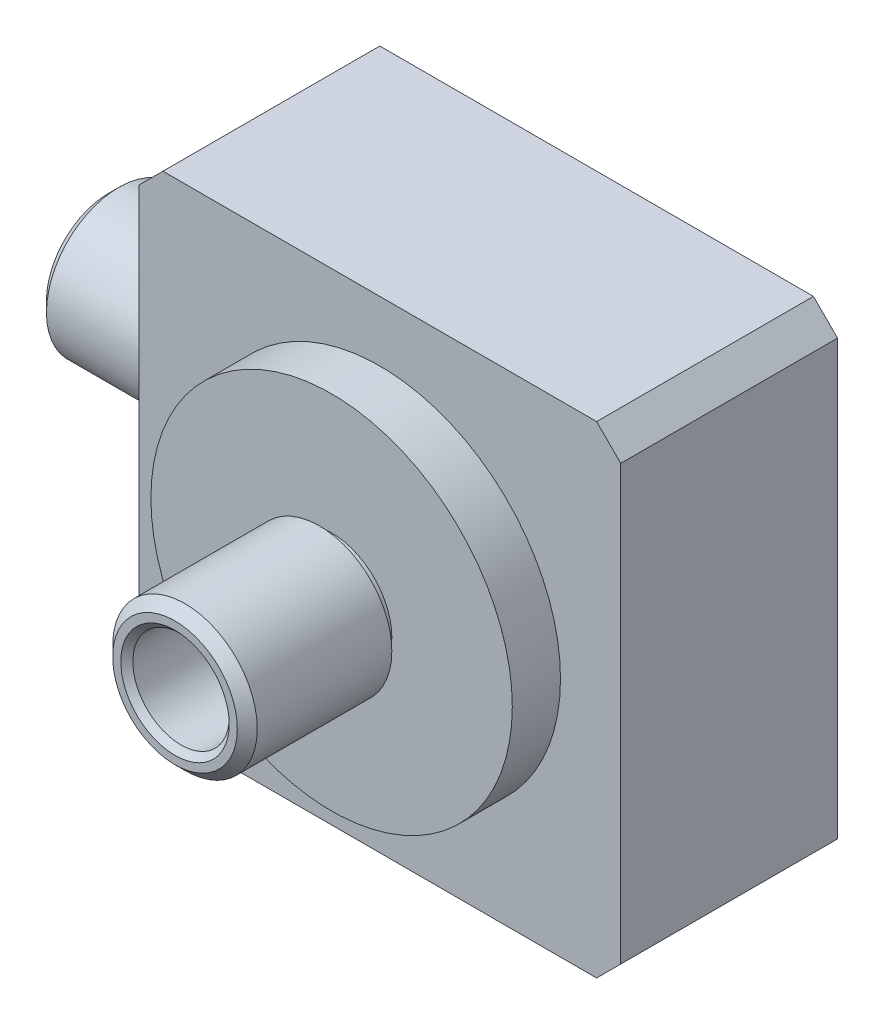
from build123d import *

# Parameters (mm, degrees)
SKETCH_1_W          = 40
SKETCH_1_H          = 40
EXTRUDE_1_DEPTH     = 18
SKETCH_2_R          = 15
EXTRUDE_2_DEPTH     = 4
SKETCH_3_R          = 5
EXTRUDE_3_DEPTH     = 1
SKETCH_4_R          = 6
EXTRUDE_4_DEPTH     = 12
SKETCH_5_R          = 5
EXTRUDE_5_DEPTH     = 1
SKETCH_6_R          = 6
EXTRUDE_6_DEPTH     = 12.5
SKETCH_8_R          = 2.5
CUT_EXTRUDE_1_DEPTH = 36
SKETCH_9_R          = 4
CUT_EXTRUDE_2_DEPTH = 10
CUT_EXTRUDE_3_REACH = 55.5
SKETCH_10_R         = 2.5
SKETCH_11_R         = 4
CUT_EXTRUDE_4_DEPTH = 10
CHAMFER_1_SIZE      = 0.5
CHAMFER_2_SIZE      = 0.828
CHAMFER_3_SIZE      = 2


with BuildPart() as part:
    # Эскиз1 → Бобышка-Вытянуть1 (new body)
    with BuildSketch(Plane.XY):
        Rectangle(SKETCH_1_W, SKETCH_1_H)
    extrude(amount=EXTRUDE_1_DEPTH)

    # Эскиз2 → Бобышка-Вытянуть2 (add)
    with BuildSketch(Plane.XY.offset(18)):
        Circle(SKETCH_2_R)
    extrude(amount=EXTRUDE_2_DEPTH)

    # Эскиз3 → Бобышка-Вытянуть3 (add)
    with BuildSketch(Plane.XY.offset(22)):
        Circle(SKETCH_3_R)
    extrude(amount=EXTRUDE_3_DEPTH)

    # Эскиз4 → Бобышка-Вытянуть4 (add)
    with BuildSketch(Plane.XY.offset(23)):
        Circle(SKETCH_4_R)
    extrude(amount=EXTRUDE_4_DEPTH)

    # Эскиз5 → Бобышка-Вытянуть5 (add)
    with BuildSketch(Plane.ZY.offset(20)):
        with Locations((7, 0)):
            Circle(SKETCH_5_R)
    extrude(amount=EXTRUDE_5_DEPTH)

    # Эскиз6 → Бобышка-Вытянуть6 (add)
    with BuildSketch(Plane.ZY.offset(21)):
        with Locations((7, 0)):
            Circle(SKETCH_6_R)
    extrude(amount=EXTRUDE_6_DEPTH)

    # Эскиз7 → Вырез-Повернуть1 (revolve, cut)
    with BuildSketch(Plane(origin=(0, 0, 0), x_dir=(1, 0, 0), z_dir=(0, 1, 0))):
        Polygon((0, 0), (0, -8), (3.5, -8), (8.696152423, -11), (11, -11), (11, 0), align=None)
    revolve(axis=Axis((0, 0, 0), (0, 0, 1)), mode=Mode.SUBTRACT)

    # Эскиз8 → Вырез-Вытянуть1 (cut, through all)
    with BuildSketch(Plane.XY.offset(35)):
        Circle(SKETCH_8_R)
    extrude(amount=-CUT_EXTRUDE_1_DEPTH, mode=Mode.SUBTRACT)

    # Эскиз9 → Вырез-Вытянуть2 (cut)
    with BuildSketch(Plane.XY.offset(35)):
        Circle(SKETCH_9_R)
    extrude(amount=-CUT_EXTRUDE_2_DEPTH, mode=Mode.SUBTRACT)

    # Эскиз10 → Вырез-Вытянуть3 (cut, up to next)
    with BuildSketch(Plane.ZY.offset(33.5), mode=Mode.PRIVATE) as cut_extrude_3_sk1:
        with Locations((7, 0)):
            Circle(SKETCH_10_R)
    cut_extrude_3_tool1 = extrude(cut_extrude_3_sk1.sketch, amount=-CUT_EXTRUDE_3_REACH, mode=Mode.PRIVATE) & part.part
    add(cut_extrude_3_tool1.solids().sort_by_distance((-33.5, 0, 7))[0], mode=Mode.SUBTRACT)

    # Эскиз11 → Вырез-Вытянуть4 (cut)
    with BuildSketch(Plane.ZY.offset(33.5)):
        with Locations((7, 0)):
            Circle(SKETCH_11_R)
    extrude(amount=-CUT_EXTRUDE_4_DEPTH, mode=Mode.SUBTRACT)

    # Фаска1
    chamfer_1_edges = [part.edges().sort_by_distance(p)[0] for p in [
        (-4, 0, 35),
        (-33.5, 0, 3),
    ]]
    chamfer(chamfer_1_edges, length=CHAMFER_1_SIZE)

    # Фаска2
    chamfer_2_edges = [part.edges().sort_by_distance(p)[0] for p in [
        (-6, 0, 35),
        (-33.5, 0, 1),
    ]]
    chamfer(chamfer_2_edges, length=CHAMFER_2_SIZE)

    # Фаска3
    chamfer_3_edges = [part.edges().sort_by_distance(p)[0] for p in [
        (20, -20, 9),
        (-20, -20, 9),
        (-20, 20, 9),
        (20, 20, 9),
    ]]
    chamfer(chamfer_3_edges, length=CHAMFER_3_SIZE)

    # Эскиз12 → Вырез-Повернуть2 (revolve, cut)
    with BuildSketch(Plane(origin=(0, 0, 0), x_dir=(1, 0, 0), z_dir=(0, 1, 0))):
        with BuildLine():
            Line((13.5, 0), (13.5, 3))
            ThreePointArc((13.5, 3), (15.5, 5), (17.5, 3))
            Line((17.5, 3), (17.5, 0))
            ThreePointArc((17.5, 0), (15.5, -2), (13.5, 0))
        make_face()
    revolve(axis=Axis((0, 0, 0), (0, 0, 1)), mode=Mode.SUBTRACT)


solid = part.part
